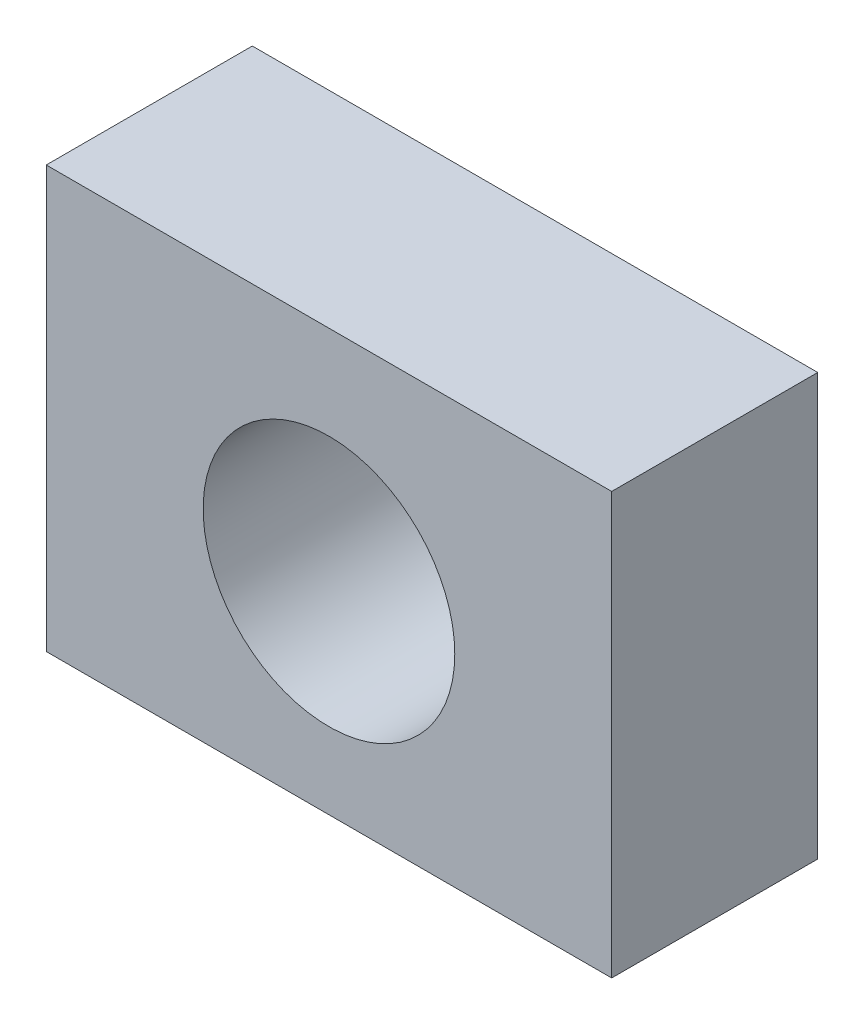
from build123d import *

# Parameters (mm, degrees)
SKETCH1_W           = 68.601004991
SKETCH1_H           = 51.124703339
SKETCH1_R           = 15.263617063
BOSS_EXTRUDE1_DEPTH = 25


with BuildPart() as part:
    # Sketch1 → Boss-Extrude1 (new body)
    with BuildSketch(Plane.XY):
        with Locations((3.130083878, 1.043361293)):
            Rectangle(SKETCH1_W, SKETCH1_H)
        with Locations((3.130083878, 0)):
            Circle(SKETCH1_R, mode=Mode.SUBTRACT)
    extrude(amount=BOSS_EXTRUDE1_DEPTH)


solid = part.part
